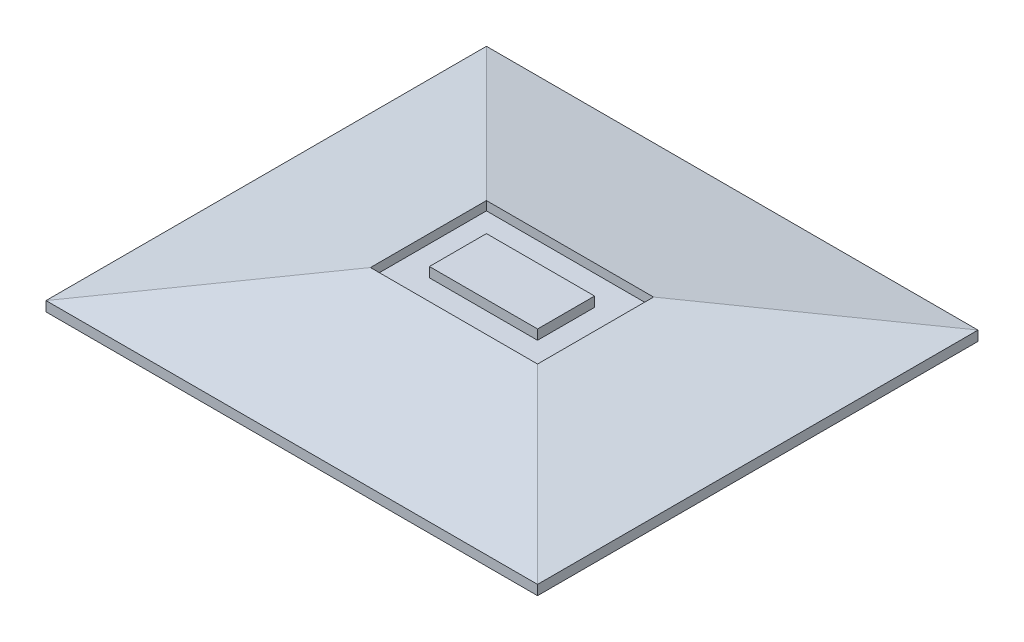
from build123d import *

# Parameters (mm, degrees)
SKETCH1_W             = 50
SKETCH1_H             = 44.8
BOSS_EXTRUDE1_DEPTH   = 4
CHAMFER1_SIZE         = 3
CHAMFER1_SIZE2        = 17.013845459
CHAMFER1_PART_2_SIZE  = 3
CHAMFER1_PART_2_SIZE2 = 17.013845459
CHAMFER1_PART_3_SIZE  = 3
CHAMFER1_PART_3_SIZE2 = 17.013845459
CHAMFER1_PART_4_SIZE  = 3
CHAMFER1_PART_4_SIZE2 = 17.013845459
SKETCH2_W             = 17
SKETCH2_H             = 11.8
SKETCH2_W_2           = 11
SKETCH2_H_2           = 5.8
CUT_EXTRUDE1_DEPTH    = 1
SKETCH3_W             = 10.2
SKETCH3_H             = 5.1
CUT_EXTRUDE2_DEPTH    = 3
SKETCH5_W             = 11
SKETCH5_H             = 5.8
BOSS_EXTRUDE2_DEPTH   = 1


with BuildPart() as part:
    # Sketch1 → Boss-Extrude1 (new body)
    with BuildSketch(Plane(origin=(0, 0, 0), x_dir=(1, 0, 0), z_dir=(0, 1, 0))):
        with Locations((25, -22.4)):
            Rectangle(SKETCH1_W, SKETCH1_H)
    extrude(amount=BOSS_EXTRUDE1_DEPTH)

    # Chamfer1
    chamfer1_edges = [part.edges().sort_by_distance(p)[0] for p in [
        (50, 4, 22.4),
    ]]
    chamfer1_side = [part.faces().sort_by_distance(p)[0] for p in [
        (50, 2, 22.4),
    ]]
    chamfer(chamfer1_edges, length=CHAMFER1_SIZE, length2=CHAMFER1_SIZE2, reference=chamfer1_side[0])

    # Chamfer1 part 2
    chamfer1_part_2_edges = [part.edges().sort_by_distance(p)[0] for p in [
        (25, 4, 0),
    ]]
    chamfer1_part_2_side = [part.faces().sort_by_distance(p)[0] for p in [
        (25, 2, 0),
    ]]
    chamfer(chamfer1_part_2_edges, length=CHAMFER1_PART_2_SIZE, length2=CHAMFER1_PART_2_SIZE2, reference=chamfer1_part_2_side[0])

    # Chamfer1 part 3
    chamfer1_part_3_edges = [part.edges().sort_by_distance(p)[0] for p in [
        (0, 4, 22.4),
    ]]
    chamfer1_part_3_side = [part.faces().sort_by_distance(p)[0] for p in [
        (0, 2, 22.4),
    ]]
    chamfer(chamfer1_part_3_edges, length=CHAMFER1_PART_3_SIZE, length2=CHAMFER1_PART_3_SIZE2, reference=chamfer1_part_3_side[0])

    # Chamfer1 part 4
    chamfer1_part_4_edges = [part.edges().sort_by_distance(p)[0] for p in [
        (25, 4, 44.8),
    ]]
    chamfer1_part_4_side = [part.faces().sort_by_distance(p)[0] for p in [
        (25, 2, 44.8),
    ]]
    chamfer(chamfer1_part_4_edges, length=CHAMFER1_PART_4_SIZE, length2=CHAMFER1_PART_4_SIZE2, reference=chamfer1_part_4_side[0])

    # Sketch2 → Cut-Extrude1 (cut)
    with BuildSketch(Plane(origin=(0, 4, 0), x_dir=(1, 0, 0), z_dir=(0, 1, 0))):
        with Locations((25, -22.4)):
            Rectangle(SKETCH2_W, SKETCH2_H)
        with Locations((25, -22.4)):
            Rectangle(SKETCH2_W_2, SKETCH2_H_2, mode=Mode.SUBTRACT)
    extrude(amount=-CUT_EXTRUDE1_DEPTH, mode=Mode.SUBTRACT)

    # Sketch3 → Cut-Extrude2 (cut)
    with BuildSketch(Plane(origin=(0, 4, 0), x_dir=(1, 0, 0), z_dir=(0, 1, 0))):
        with Locations((25, -22.45)):
            Rectangle(SKETCH3_W, SKETCH3_H)
    extrude(amount=-CUT_EXTRUDE2_DEPTH, mode=Mode.SUBTRACT)

    # Sketch5 → Boss-Extrude2 (add)
    with BuildSketch(Plane(origin=(0, 4, 0), x_dir=(1, 0, 0), z_dir=(0, 1, 0))):
        with Locations((25, -22.4)):
            Rectangle(SKETCH5_W, SKETCH5_H)
    extrude(amount=-BOSS_EXTRUDE2_DEPTH)


solid = part.part
